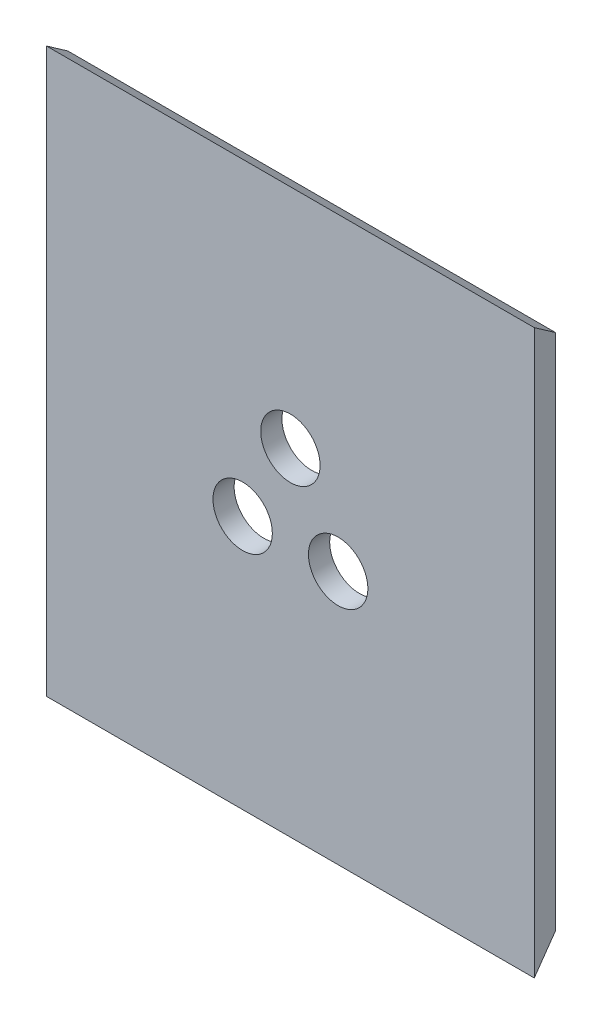
from build123d import *

# Parameters (mm, degrees)
SKETCH1_W           = 115
SKETCH1_H           = 132.8
SKETCH1_R           = 7
BOSS_EXTRUDE1_DEPTH = 5
CUT_EXTRUDE1_REACH  = 117
CUT_EXTRUDE2_REACH  = 117


with BuildPart() as part:
    # Sketch1 → Boss-Extrude1 (new body)
    with BuildSketch(Plane.XY):
        Rectangle(SKETCH1_W, SKETCH1_H)
        with Locations((0, 13)):
            Circle(SKETCH1_R, mode=Mode.SUBTRACT)
        with Locations((-11.258330249, -6.5)):
            Circle(SKETCH1_R, mode=Mode.SUBTRACT)
        with Locations((11.258330249, -6.5)):
            Circle(SKETCH1_R, mode=Mode.SUBTRACT)
    extrude(amount=BOSS_EXTRUDE1_DEPTH)

    # Sketch2 → Cut-Extrude1 (cut, up to next)
    with BuildSketch(Plane(origin=(57.5, 0, 0), x_dir=(0, 0, -1), z_dir=(1, 0, 0)), mode=Mode.PRIVATE) as cut_extrude1_sk1:
        Polygon((-5, -66.4), (0, -66.4), (0, -59.259259966), align=None)
    cut_extrude1_tool1 = extrude(cut_extrude1_sk1.sketch, amount=-CUT_EXTRUDE1_REACH, mode=Mode.PRIVATE) & part.part
    add(cut_extrude1_tool1.solids().sort_by_distance((57.5, -64.019753, 1.666667))[0], mode=Mode.SUBTRACT)

    # Sketch3 → Cut-Extrude2 (cut, up to next)
    with BuildSketch(Plane(origin=(57.5, 0, 0), x_dir=(0, 0, -1), z_dir=(1, 0, 0)), mode=Mode.PRIVATE) as cut_extrude2_sk1:
        Polygon((-5, 66.4), (0, 66.4), (0, 62.898962309), align=None)
    cut_extrude2_tool1 = extrude(cut_extrude2_sk1.sketch, amount=-CUT_EXTRUDE2_REACH, mode=Mode.PRIVATE) & part.part
    add(cut_extrude2_tool1.solids().sort_by_distance((57.5, 65.232987, 1.666667))[0], mode=Mode.SUBTRACT)


solid = part.part
